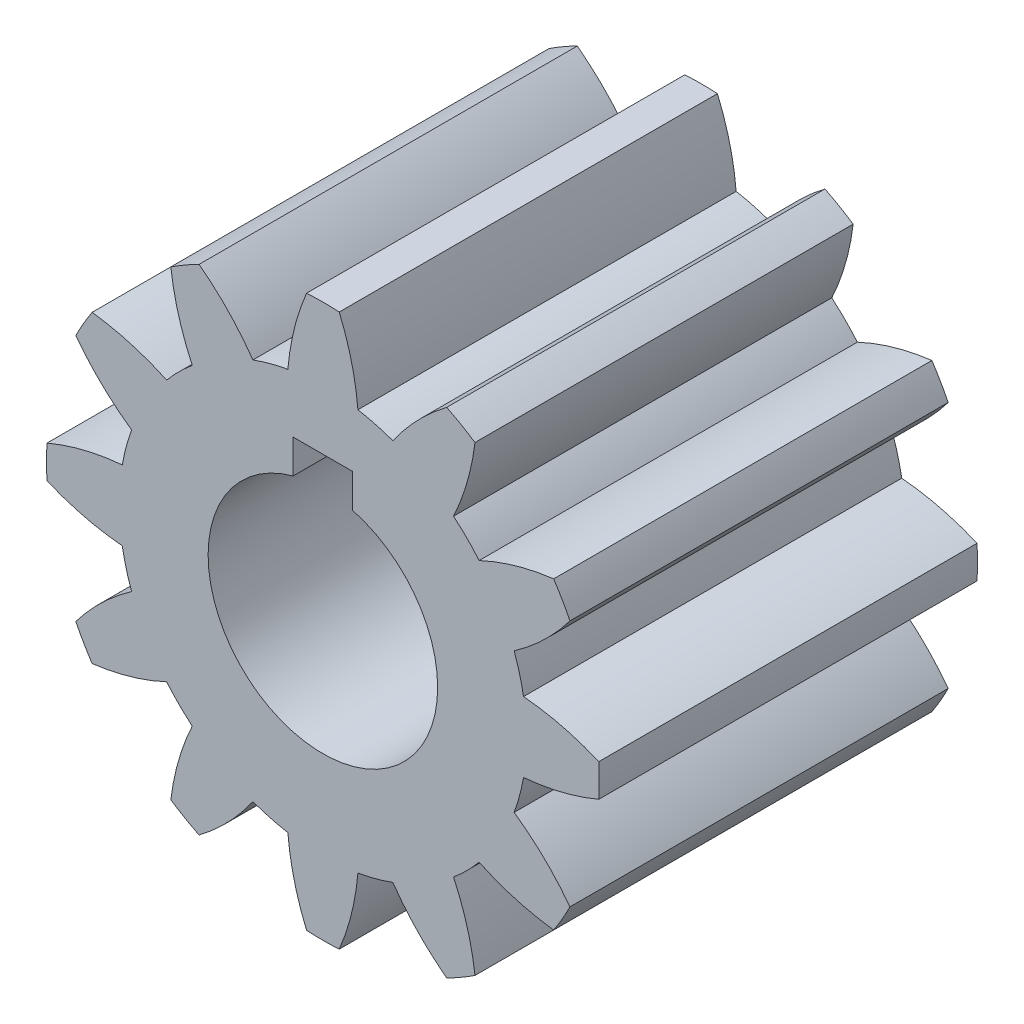
from build123d import *

# Parameters (mm, degrees)
SKETCH1_R         = 7.112
SKETCH1_R_2       = 4.00812
EXTRUDE1_DEPTH    = 6.604
EXTRUDE2_DEPTH    = 6.604
CIRPATTERN1_COUNT = 12
EXTRUDE3_DEPTH    = 14.208


with BuildPart() as part:
    # Sketch1 → Extrude1 (new body, symmetric)
    with BuildSketch(Plane.XY):
        Circle(SKETCH1_R)
        Circle(SKETCH1_R_2, mode=Mode.SUBTRACT)
    extrude(amount=EXTRUDE1_DEPTH, both=True)

    # Sketch2 → Extrude2 (add, symmetric)
    with BuildSketch(Plane.XY):
        with BuildLine():
            ThreePointArc((-1.223214196, 7.006018201), (0, 7.112), (1.223214196, 7.006018201))
            ThreePointArc((1.223214196, 7.006018201), (1.000294904, 8.346410328), (0.569675744, 9.635173768))
            ThreePointArc((0.569675744, 9.635173768), (0, 9.652), (-0.569675744, 9.635173768))
            ThreePointArc((-0.569675744, 9.635173768), (-1.000294904, 8.346410328), (-1.223214196, 7.006018201))
        make_face()
    extrude2 = extrude(amount=EXTRUDE2_DEPTH, both=True)

    # CirPattern1: Extrude2 ×12 about axis
    cirpattern1_axis = Axis((0, 0, 0), (0, 0, 1))
    for i in range(1, CIRPATTERN1_COUNT):
        add(extrude2.rotate(cirpattern1_axis, i * 360 / CIRPATTERN1_COUNT))

    # Sketch3 → Extrude3 (cut, through all)
    with BuildSketch(Plane.XY.offset(6.604)):
        with BuildLine():
            Line((-1.0414, 3.870466635), (-1.0414, 5.04825))
            Line((-1.0414, 5.04825), (1.0414, 5.04825))
            Line((1.0414, 5.04825), (1.0414, 3.870466635))
            ThreePointArc((1.0414, 3.870466635), (0, 4.00812), (-1.0414, 3.870466635))
        make_face()
    extrude(amount=-EXTRUDE3_DEPTH, mode=Mode.SUBTRACT)


solid = part.part
